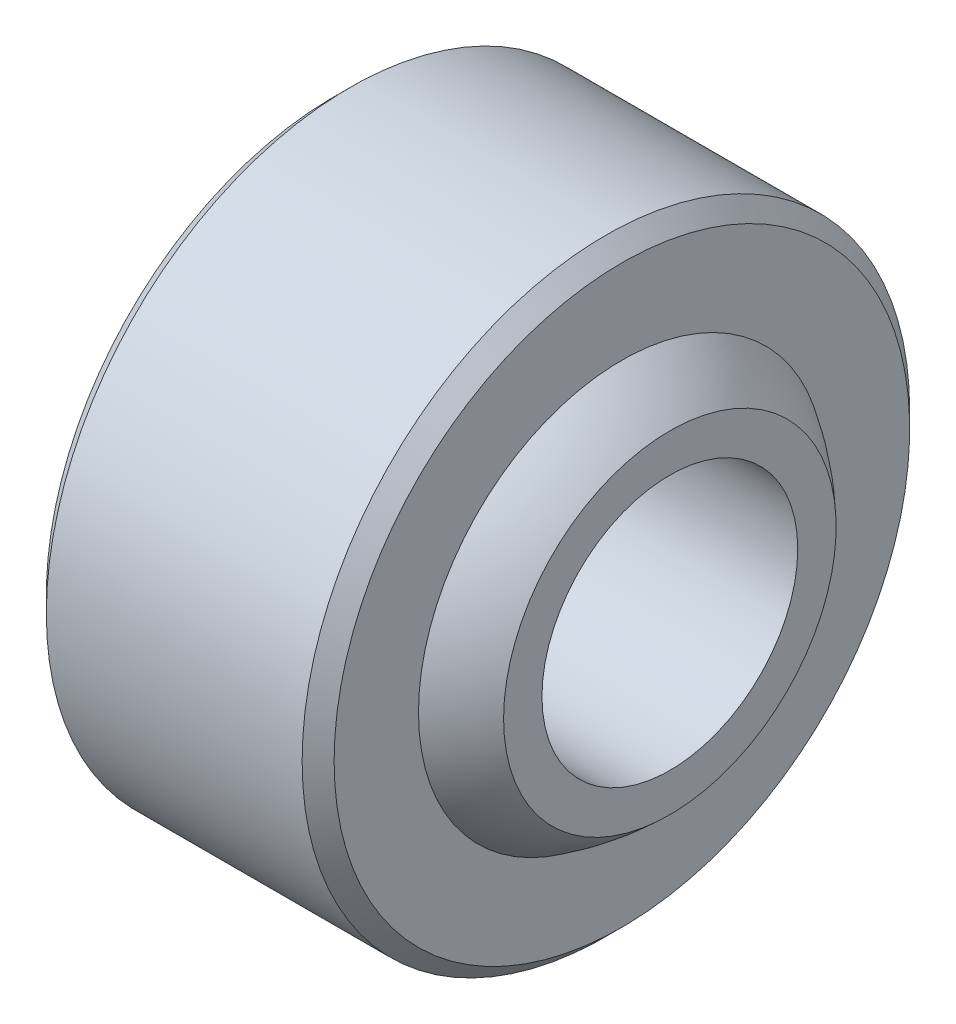
from build123d import *

# Parameters (mm, degrees)
SFAZOWANIE1_SIZE = 0.5


with BuildPart() as part:
    # Szkic1 → Obrót1 (revolve)
    with BuildSketch(Plane.XY):
        with BuildLine():
            Line((-6, 0), (6, 0))
            Line((6, 0), (6, 1.2))
            ThreePointArc((6, 1.2), (5.282017059, 1.822044839), (4.5, 2.361385739))
            Line((4.5, 2.361385739), (4.5, 5.5))
            Line((4.5, 5.5), (-4.5, 5.5))
            Line((-4.5, 5.5), (-4.5, 2.361385739))
            ThreePointArc((-4.5, 2.361385739), (-5.282017059, 1.822044839), (-6, 1.2))
            Line((-6, 1.2), (-6, 0))
        make_face()
    revolve(axis=Axis((-11.261323988, -4, 0), (1, 0, 0)))

    # Sfazowanie1
    sfazowanie1_edges = [part.edges().sort_by_distance(p)[0] for p in [
        (-4.5, -13.5, 0),
        (4.5, -13.5, 0),
    ]]
    chamfer(sfazowanie1_edges, length=SFAZOWANIE1_SIZE)


solid = part.part
